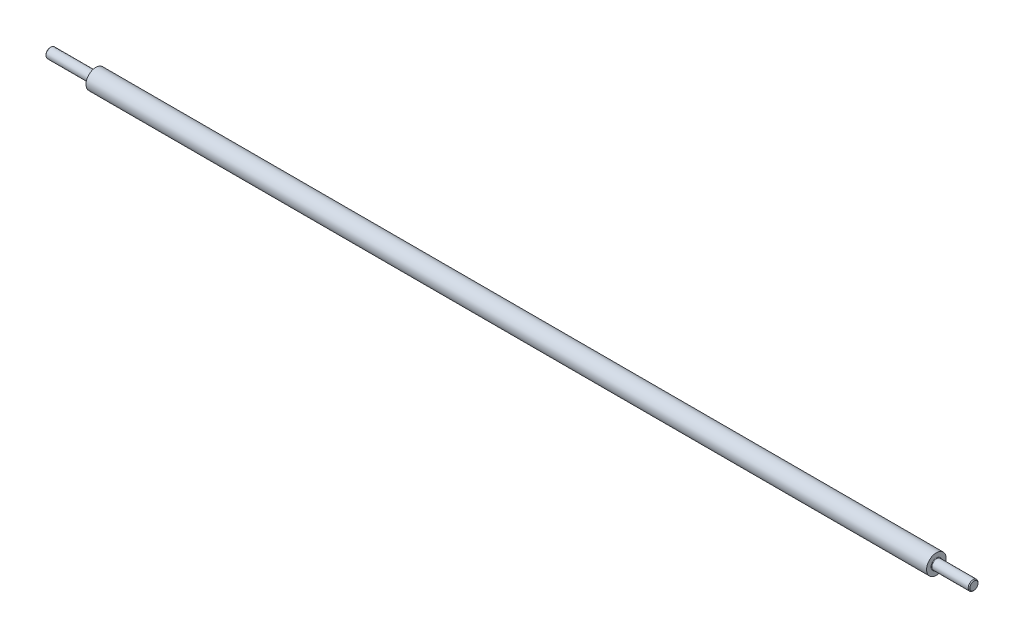
from build123d import *

# Parameters (mm, degrees)
CHAMFER1_SIZE = 0.5
FILLET1_R     = 0.3


with BuildPart() as part:
    # Sketch1 → Revolve1 (revolve)
    with BuildSketch(Plane.XY):
        Polygon((-608.6, 54.57), (-636.6, 54.57), (-636.6, 51.57), (-70.6, 51.57), (-70.6, 54.57), (-93.6, 54.57), (-93.6, 57.57), (-608.6, 57.57), align=None)
    revolve(axis=Axis((-24.960657764, 51.57, 0), (-1, 0, 0)))

    # Chamfer1
    chamfer1_edges = [part.edges().sort_by_distance(p)[0] for p in [
        (-70.6, 48.57, 0),
        (-636.6, 48.57, 0),
    ]]
    chamfer(chamfer1_edges, length=CHAMFER1_SIZE)

    # Fillet1
    fillet1_edges = [part.edges().sort_by_distance(p)[0] for p in [
        (-93.6, 48.57, 0),
        (-608.6, 48.57, 0),
    ]]
    fillet(fillet1_edges, radius=FILLET1_R)


solid = part.part
